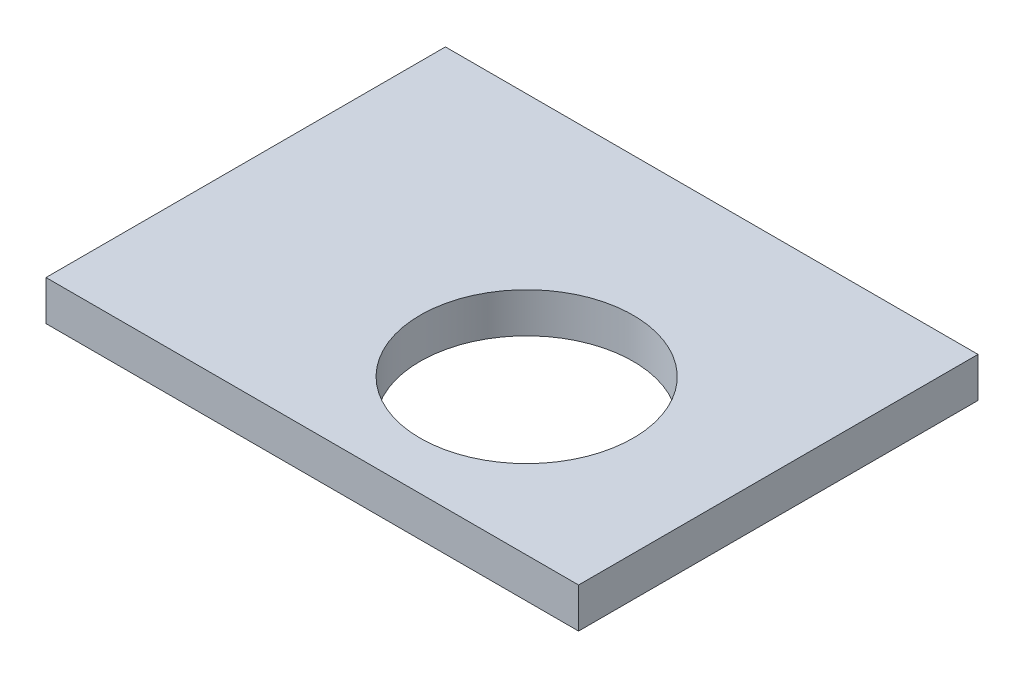
from build123d import *

# Parameters (mm, degrees)
SKETCH1_W           = 80
SKETCH1_H           = 60
SKETCH1_R           = 16
BOSS_EXTRUDE1_DEPTH = 6


with BuildPart() as part:
    # Sketch1 → Boss-Extrude1 (new body)
    with BuildSketch(Plane(origin=(0, 0, 0), x_dir=(1, 0, 0), z_dir=(0, 1, 0))):
        with Locations((40, 30)):
            Rectangle(SKETCH1_W, SKETCH1_H)
        with Locations((49, 23.2)):
            Circle(SKETCH1_R, mode=Mode.SUBTRACT)
    extrude(amount=BOSS_EXTRUDE1_DEPTH)


solid = part.part
